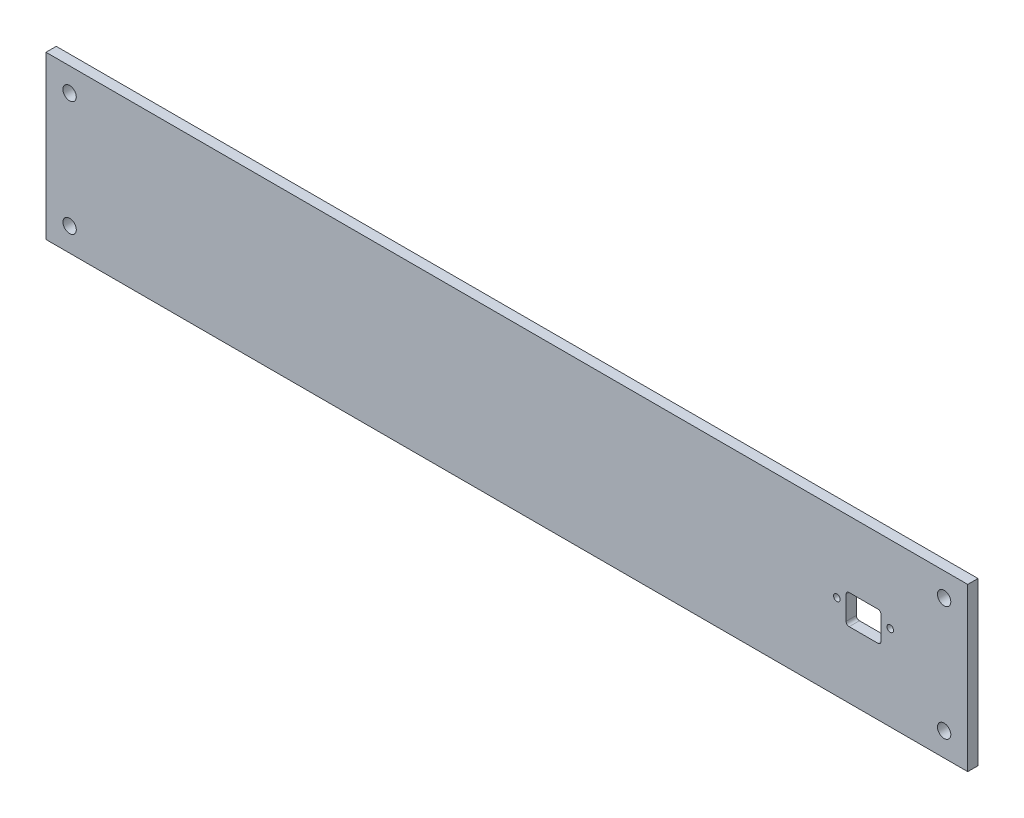
from build123d import *

# Parameters (mm, degrees)
SKETCH_F_W                   = 449
SKETCH_F_H                   = 79
SKETCH_F_R                   = 3.25
SKETCH_F_R_2                 = 1.6
ESTRUSIONE_ESTRUSIONE1_DEPTH = 5


with BuildPart() as part:
    # Sketch f → Estrusione-Estrusione1 (new body)
    with BuildSketch(Plane.XY):
        with Locations((224.5, 39.5)):
            Rectangle(SKETCH_F_W, SKETCH_F_H)
        with Locations((11.5, 67.5)):
            Circle(SKETCH_F_R, mode=Mode.SUBTRACT)
        with Locations((437.5, 67.5)):
            Circle(SKETCH_F_R, mode=Mode.SUBTRACT)
        with Locations((11.5, 11.5)):
            Circle(SKETCH_F_R, mode=Mode.SUBTRACT)
        with Locations((437.5, 11.5)):
            Circle(SKETCH_F_R, mode=Mode.SUBTRACT)
        with Locations((385.246939646, 41.5)):
            Circle(SKETCH_F_R_2, mode=Mode.SUBTRACT)
        with Locations((411.246939646, 41.5)):
            Circle(SKETCH_F_R_2, mode=Mode.SUBTRACT)
        with BuildLine():
            Line((406.746939646, 33.8), (406.746939646, 45.2))
            ThreePointArc((406.746939646, 45.2), (406.307599818, 46.260660172), (405.246939646, 46.7))
            Line((405.246939646, 46.7), (391.246939646, 46.7))
            ThreePointArc((391.246939646, 46.7), (390.186279474, 46.260660172), (389.746939646, 45.2))
            Line((389.746939646, 45.2), (389.746939646, 33.8))
            ThreePointArc((389.746939646, 33.8), (390.186279474, 32.739339828), (391.246939646, 32.3))
            Line((391.246939646, 32.3), (405.246939646, 32.3))
            ThreePointArc((405.246939646, 32.3), (406.307599818, 32.739339828), (406.746939646, 33.8))
        make_face(mode=Mode.SUBTRACT)
    extrude(amount=ESTRUSIONE_ESTRUSIONE1_DEPTH)


solid = part.part
